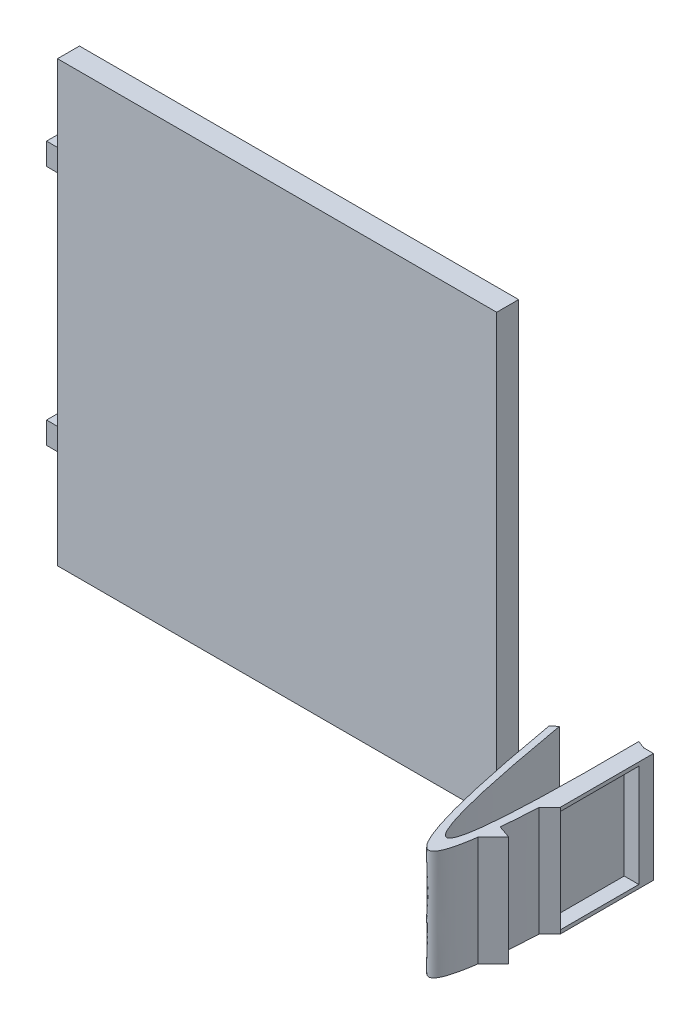
from build123d import *

# Parameters (mm, degrees)
ESQUISSE2_W             = 60
ESQUISSE2_H             = 60
BOSS_EXTRU_5_DEPTH      = 3
ESQUISSE4_W             = 3
ESQUISSE4_H             = 3
BOSS_EXTRU_6_DEPTH      = 1.5
BOSS_EXTRU_7_DEPTH      = 15
ESQUISSE6_W             = 10.73554263
ESQUISSE6_H             = 14
ENL_V_MAT_EXTRU_3_DEPTH = 2


with BuildPart() as part:
    # Esquisse2 → Boss.-Extru.5 (new body)
    with BuildSketch(Plane.XY):
        with Locations((-92.529091576, 26.952913469)):
            Rectangle(ESQUISSE2_W, ESQUISSE2_H)
    extrude(amount=BOSS_EXTRU_5_DEPTH)

    # Esquisse4 → Boss.-Extru.6 (add)
    with BuildSketch(Plane.XY):
        with Locations((-124.029091576, 43.452913469)):
            Rectangle(ESQUISSE4_W, ESQUISSE4_H)
        with Locations((-124.029091576, 10.452913469)):
            Rectangle(ESQUISSE4_W, ESQUISSE4_H)
    extrude(amount=BOSS_EXTRU_6_DEPTH)


with BuildPart() as body_2:
    # Esquisse5 → Boss.-Extru.7 (new body)
    with BuildSketch(Plane(origin=(0, 0, 0), x_dir=(1, 0, 0), z_dir=(0, 1, 0))):
        with BuildLine():
            add(Edge.make_bspline(
                [(-51.196275426, -5.778879221), (-43.615971935, -49.182959999), (-43.988419185, -2.128215511)],
                knots=[0, 0, 0, 1, 1, 1], degree=2))
            Line((-43.988419185, -2.128215511), (-42.89303889, -2.537863847))
            add(Edge.make_bspline(
                [(-51.966076605, -6.370882605), (-43.906365512, -52.160925825), (-42.431120628, -17.92359053), (-42.89303889, -2.537863847)],
                knots=[0, 0, 0, 0, 1, 1, 1, 1], degree=3))
            Line((-51.966076605, -6.370882605), (-51.196275426, -5.778879221))
        make_face()
        with BuildLine():
            add(Edge.make_bspline(
                [(-43.655572035, -24.398887349), (-43.539836944, -23.57085318), (-43.437699228, -22.664594203), (-43.348190801, -21.700707969)],
                knots=[0.584216968, 0.584216968, 0.584216968, 0.584216968, 0.643496376, 0.643496376, 0.643496376, 0.643496376], degree=3))
            Line((-43.655572035, -24.398887349), (-41.570382682, -22.313697996))
            Line((-41.570382682, -22.313697996), (-43.348190801, -21.700707969))
        make_face()
        with BuildLine():
            add(Edge.make_bspline(
                [(-43.011516669, -16.714540464), (-42.78393513, -11.879120869), (-42.772185803, -6.563278554), (-42.89303889, -2.537863847)],
                knots=[0.738366943, 0.738366943, 0.738366943, 0.738366943, 1, 1, 1, 1], degree=3))
            Line((-43.011516669, -16.714540464), (-41.570382682, -15.273406477))
            Line((-41.570382682, -15.273406477), (-41.570382682, -2.537863847))
            Line((-41.570382682, -2.537863847), (-42.89303889, -2.537863847))
        make_face()
    extrude(amount=BOSS_EXTRU_7_DEPTH)

    # Esquisse6 → Enlèv. mat.-Extru.3 (cut)
    with BuildSketch(Plane(origin=(-41.570382682, 0, 0), x_dir=(0, 0, -1), z_dir=(1, 0, 0))):
        with Locations((-9.905635162, 7.5)):
            Rectangle(ESQUISSE6_W, ESQUISSE6_H)
    extrude(amount=-ENL_V_MAT_EXTRU_3_DEPTH, mode=Mode.SUBTRACT)


solid = Compound([part.part, body_2.part])
